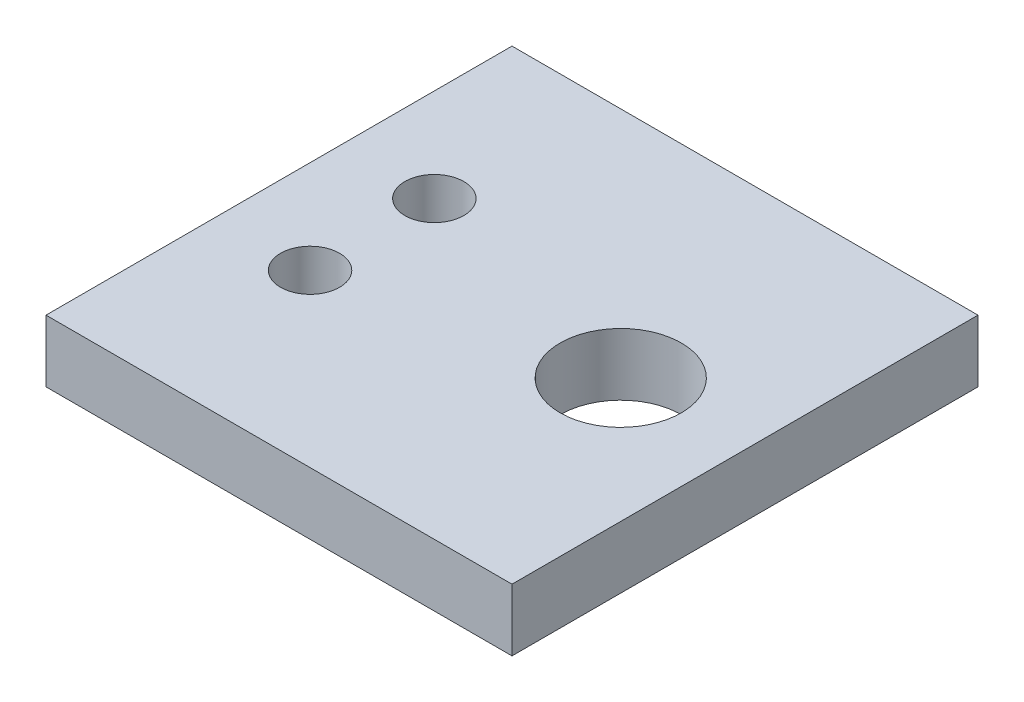
from build123d import *

# Parameters (mm, degrees)
SKETCH2_W           = 15
SKETCH2_H           = 15
BOSS_EXTRUDE1_DEPTH = 2
SKETCH3_R           = 0.95
CUT_EXTRUDE1_DEPTH  = 2
SKETCH4_R           = 1.95
CUT_EXTRUDE2_DEPTH  = 2


with BuildPart() as part:
    # Sketch2 → Boss-Extrude1 (new body)
    with BuildSketch(Plane(origin=(0, 0, 0), x_dir=(1, 0, 0), z_dir=(0, 1, 0))):
        Rectangle(SKETCH2_W, SKETCH2_H)
    extrude(amount=BOSS_EXTRUDE1_DEPTH)

    # Sketch3 → Cut-Extrude1 (cut)
    with BuildSketch(Plane(origin=(0, 2, 0), x_dir=(1, 0, 0), z_dir=(0, 1, 0))):
        with Locations((-4.5, -2)):
            Circle(SKETCH3_R)
        with Locations((-4.5, 2)):
            Circle(SKETCH3_R)
    extrude(amount=-CUT_EXTRUDE1_DEPTH, mode=Mode.SUBTRACT)

    # Sketch4 → Cut-Extrude2 (cut)
    with BuildSketch(Plane(origin=(0, 2, 0), x_dir=(1, 0, 0), z_dir=(0, 1, 0))):
        with Locations((3.5, 0)):
            Circle(SKETCH4_R)
    extrude(amount=-CUT_EXTRUDE2_DEPTH, mode=Mode.SUBTRACT)


solid = part.part
